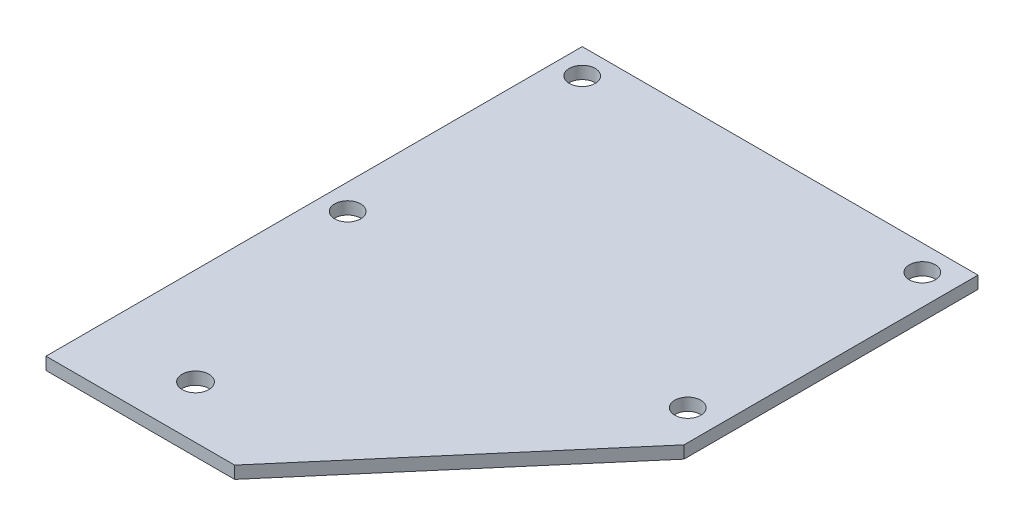
from build123d import *

# Parameters (mm, degrees)
SKETCH1_R           = 3.33
SKETCH1_R_2         = 3.42
BOSS_EXTRUDE1_DEPTH = 3.175


with BuildPart() as part:
    # Sketch1 → Boss-Extrude1 (new body)
    with BuildSketch(Plane(origin=(0, 0, 0), x_dir=(1, 0, 0), z_dir=(0, 1, 0))):
        Polygon((0, -68.58), (0, 68.58), (101.24, 68.58), (101.24, -6.62), (48.26, -68.58), align=None)
        with Locations((93.5, 62.08)):
            Circle(SKETCH1_R, mode=Mode.SUBTRACT)
        with Locations((6.5, 62.08)):
            Circle(SKETCH1_R, mode=Mode.SUBTRACT)
        with Locations((93.5, 2.08)):
            Circle(SKETCH1_R, mode=Mode.SUBTRACT)
        with Locations((6.5, 2.08)):
            Circle(SKETCH1_R, mode=Mode.SUBTRACT)
        with Locations((24.82, -55.16)):
            Circle(SKETCH1_R_2, mode=Mode.SUBTRACT)
    extrude(amount=BOSS_EXTRUDE1_DEPTH)


solid = part.part
